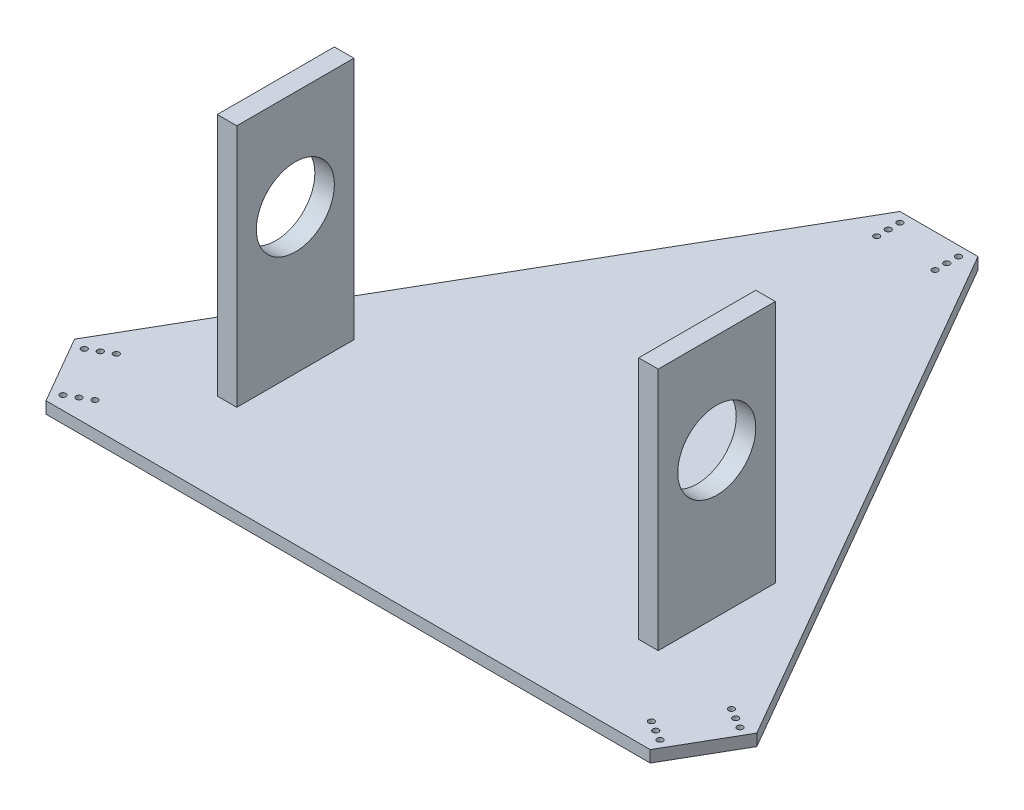
from build123d import *

# Parameters (mm, degrees)
BOSS_EXTRUDE2_DEPTH = 6
SKETCH9_R           = 1.5
CUT_EXTRUDE1_DEPTH  = 7
SKETCH10_W          = 10
SKETCH10_H          = 60
BOSS_EXTRUDE3_DEPTH = 125
SKETCH11_R          = 20
CUT_EXTRUDE2_DEPTH  = 288.855715857


with BuildPart() as part:
    # Sketch8 → Boss-Extrude2 (new body)
    with BuildSketch(Plane(origin=(0, 0, 0), x_dir=(1, 0, 0), z_dir=(0, 1, 0))):
        Polygon((-20, 190.358983854), (20, 190.358983854), (174.855715857, -77.858983852), (154.855715857, -112.500000003), (-154.855715857, -112.500000003), (-174.855715857, -77.858983852), align=None)
    extrude(amount=BOSS_EXTRUDE2_DEPTH)

    # Sketch9 → Cut-Extrude1 (cut, through all)
    with BuildSketch(Plane(origin=(0, 6, 0), x_dir=(1, 0, 0), z_dir=(0, 1, 0))):
        with Locations((15, 185.358983854)):
            Circle(SKETCH9_R)
        with Locations((-15, 185.358983854)):
            Circle(SKETCH9_R)
        with Locations((-15, 179.358983854)):
            Circle(SKETCH9_R)
        with Locations((-15, 173.358983854)):
            Circle(SKETCH9_R)
        with Locations((15, 179.358983854)):
            Circle(SKETCH9_R)
        with Locations((15, 173.358983854)):
            Circle(SKETCH9_R)
        with Locations((153.025588838, -105.669872984)):
            Circle(SKETCH9_R)
        with Locations((168.025588838, -79.68911087)):
            Circle(SKETCH9_R)
        with Locations((162.829436415, -76.68911087)):
            Circle(SKETCH9_R)
        with Locations((157.633283992, -73.68911087)):
            Circle(SKETCH9_R)
        with Locations((147.829436415, -102.669872984)):
            Circle(SKETCH9_R)
        with Locations((142.633283992, -99.669872984)):
            Circle(SKETCH9_R)
        with Locations((-168.025588838, -79.68911087)):
            Circle(SKETCH9_R)
        with Locations((-153.025588838, -105.669872984)):
            Circle(SKETCH9_R)
        with Locations((-147.829436415, -102.669872984)):
            Circle(SKETCH9_R)
        with Locations((-142.633283992, -99.669872984)):
            Circle(SKETCH9_R)
        with Locations((-162.829436415, -76.68911087)):
            Circle(SKETCH9_R)
        with Locations((-157.633283992, -73.68911087)):
            Circle(SKETCH9_R)
    extrude(amount=-CUT_EXTRUDE1_DEPTH, mode=Mode.SUBTRACT)

    # Sketch10 → Boss-Extrude3 (add)
    with BuildSketch(Plane(origin=(0, 6, 0), x_dir=(1, 0, 0), z_dir=(0, 1, 0))):
        with Locations((-108, -36.54767864)):
            Rectangle(SKETCH10_W, SKETCH10_H)
        with Locations((108, -36.54767864)):
            Rectangle(SKETCH10_W, SKETCH10_H)
    extrude(amount=BOSS_EXTRUDE3_DEPTH)

    # Sketch11 → Cut-Extrude2 (cut, through all)
    with BuildSketch(Plane(origin=(113, 0, 0), x_dir=(0, 0, -1), z_dir=(1, 0, 0))):
        with Locations((-36.54767864, 80)):
            Circle(SKETCH11_R)
    extrude(amount=-CUT_EXTRUDE2_DEPTH, mode=Mode.SUBTRACT)


solid = part.part
